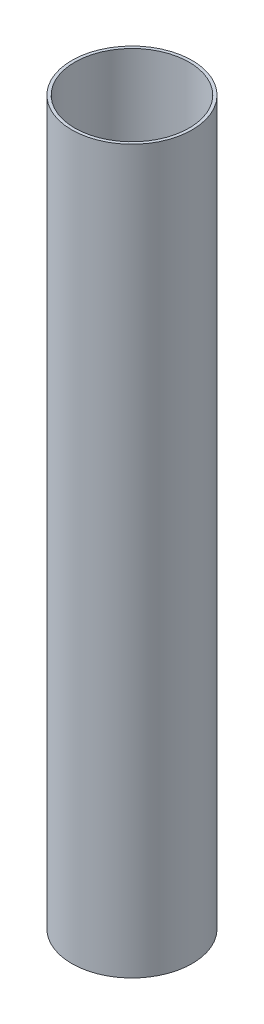
from build123d import *

# Parameters (mm, degrees)
SKETCH2_W = 3.175
SKETCH2_H = 762


with BuildPart() as part:
    # Sketch2 → Revolve1 (revolve)
    with BuildSketch(Plane.XY):
        with Locations((-61.9125, 381)):
            Rectangle(SKETCH2_W, SKETCH2_H)
    revolve(axis=Axis((0, 819.187021794, 0), (0, -1, 0)))


solid = part.part
